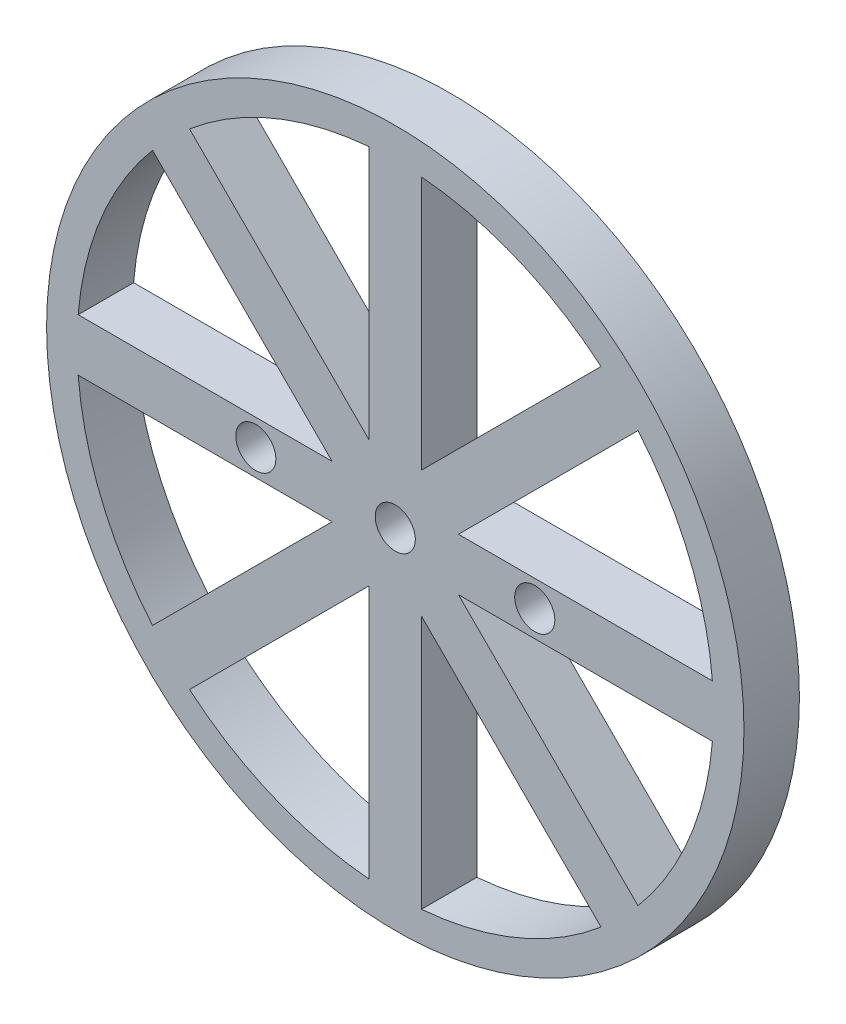
from build123d import *

# Parameters (mm, degrees)
SKETCH1_R           = 20
SKETCH1_R_2         = 1.15
BOSS_EXTRUDE1_DEPTH = 3.18


with BuildPart() as part:
    # Sketch1 → Boss-Extrude1 (new body)
    with BuildSketch(Plane.XY):
        Circle(SKETCH1_R)
        Circle(SKETCH1_R_2, mode=Mode.SUBTRACT)
        with Locations((-8, 0)):
            Circle(SKETCH1_R_2, mode=Mode.SUBTRACT)
        with Locations((8, 0)):
            Circle(SKETCH1_R_2, mode=Mode.SUBTRACT)
        with BuildLine():
            Line((-1.5, 18.188251703), (-1.5, 3.621320344))
            Line((-1.5, 3.621320344), (-11.800375945, 13.921696289))
            ThreePointArc((-11.800375945, 13.921696289), (-6.983972641, 16.860801468), (-1.5, 18.188251703))
        make_face(mode=Mode.SUBTRACT)
        with BuildLine():
            Line((-1.5, -3.621320344), (-1.5, -18.188251703))
            ThreePointArc((-1.5, -18.188251703), (-6.983972641, -16.860801468), (-11.800375945, -13.921696289))
            Line((-11.800375945, -13.921696289), (-1.5, -3.621320344))
        make_face(mode=Mode.SUBTRACT)
        with BuildLine():
            Line((1.5, -3.621320344), (1.5, -18.188251703))
            ThreePointArc((1.5, -18.188251703), (6.983972641, -16.860801468), (11.800375945, -13.921696289))
            Line((11.800375945, -13.921696289), (1.5, -3.621320344))
        make_face(mode=Mode.SUBTRACT)
        with BuildLine():
            Line((1.5, 18.188251703), (1.5, 3.621320344))
            Line((1.5, 3.621320344), (11.800375945, 13.921696289))
            ThreePointArc((11.800375945, 13.921696289), (6.983972641, 16.860801468), (1.5, 18.188251703))
        make_face(mode=Mode.SUBTRACT)
        with BuildLine():
            Line((-18.188251703, 1.5), (-3.621320344, 1.5))
            Line((-3.621320344, 1.5), (-13.921696289, 11.800375945))
            ThreePointArc((-13.921696289, 11.800375945), (-16.860801468, 6.983972641), (-18.188251703, 1.5))
        make_face(mode=Mode.SUBTRACT)
        with BuildLine():
            Line((-18.188251703, -1.5), (-3.621320344, -1.5))
            Line((-3.621320344, -1.5), (-13.921696289, -11.800375945))
            ThreePointArc((-13.921696289, -11.800375945), (-16.860801468, -6.983972641), (-18.188251703, -1.5))
        make_face(mode=Mode.SUBTRACT)
        with BuildLine():
            Line((3.621320344, 1.5), (18.188251703, 1.5))
            ThreePointArc((18.188251703, 1.5), (16.860801468, 6.983972641), (13.921696289, 11.800375945))
            Line((13.921696289, 11.800375945), (3.621320344, 1.5))
        make_face(mode=Mode.SUBTRACT)
        with BuildLine():
            Line((3.621320344, -1.5), (18.188251703, -1.5))
            ThreePointArc((18.188251703, -1.5), (16.860801468, -6.983972641), (13.921696289, -11.800375945))
            Line((13.921696289, -11.800375945), (3.621320344, -1.5))
        make_face(mode=Mode.SUBTRACT)
    extrude(amount=BOSS_EXTRUDE1_DEPTH)


solid = part.part
